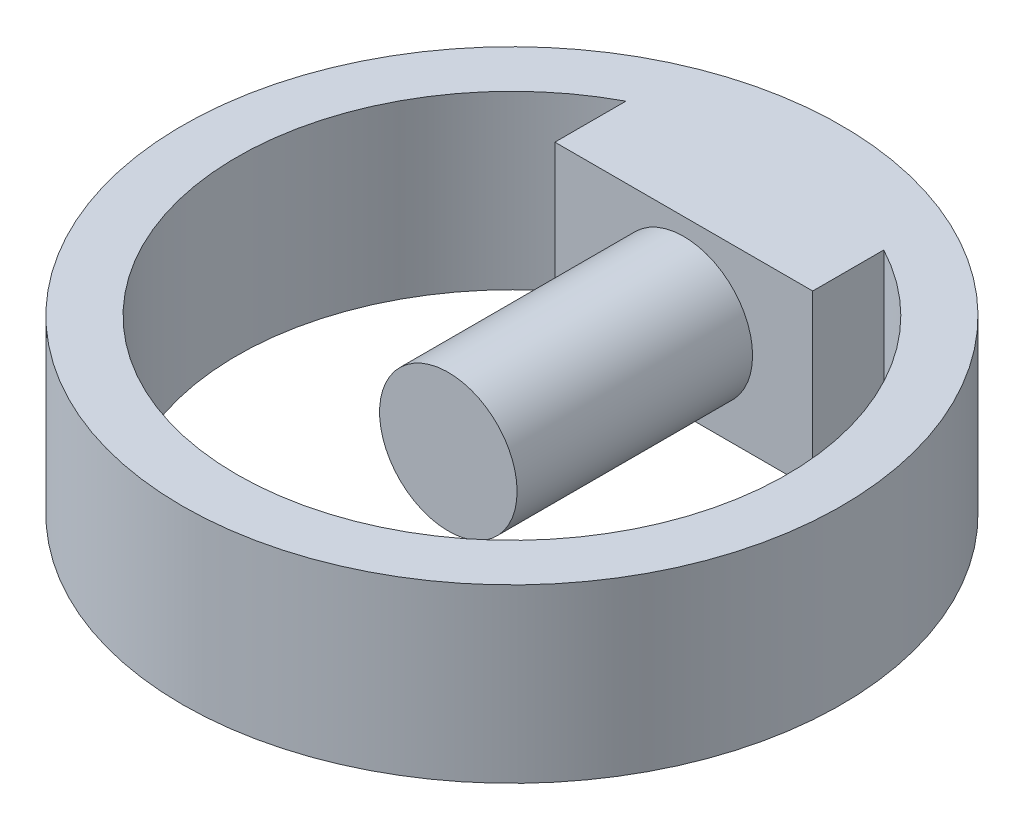
from build123d import *

# Parameters (mm, degrees)
SKETCH6_R           = 19.175
SKETCH6_R_2         = 16
BOSS_EXTRUDE4_DEPTH = 5
BOSS_EXTRUDE5_REACH = 32.265
SKETCH7_R           = 4
BOSS_EXTRUDE6_REACH = 37.268
SKETCH8_W           = 15
SKETCH8_H           = 10


with BuildPart() as part:
    # Sketch6 → Boss-Extrude4 (new, symmetric)
    with BuildSketch(Plane(origin=(0, 0, 0), x_dir=(1, 0, 0), z_dir=(0, 1, 0))):
        Circle(SKETCH6_R)
        Circle(SKETCH6_R_2, mode=Mode.SUBTRACT)
    extrude(amount=BOSS_EXTRUDE4_DEPTH, both=True)

    # Sketch7 → Boss-Extrude5 (add, up to next)
    with BuildSketch(Plane.XY.offset(3.7), mode=Mode.PRIVATE) as boss_extrude5_sk1:
        Circle(SKETCH7_R)
    boss_extrude5_tool1 = extrude(boss_extrude5_sk1.sketch, amount=-BOSS_EXTRUDE5_REACH, mode=Mode.PRIVATE) - part.part
    add(boss_extrude5_tool1.solids().sort_by_distance((0, 0, 3.7))[0])

    # Sketch8 → Boss-Extrude6 (add, up to next)
    with BuildSketch(Plane.XY.offset(-10), mode=Mode.PRIVATE) as boss_extrude6_sk1:
        Rectangle(SKETCH8_W, SKETCH8_H)
    boss_extrude6_tool1 = extrude(boss_extrude6_sk1.sketch, amount=-BOSS_EXTRUDE6_REACH, mode=Mode.PRIVATE) - part.part
    add(boss_extrude6_tool1.solids().sort_by_distance((0, 0, -10))[0])


solid = part.part
